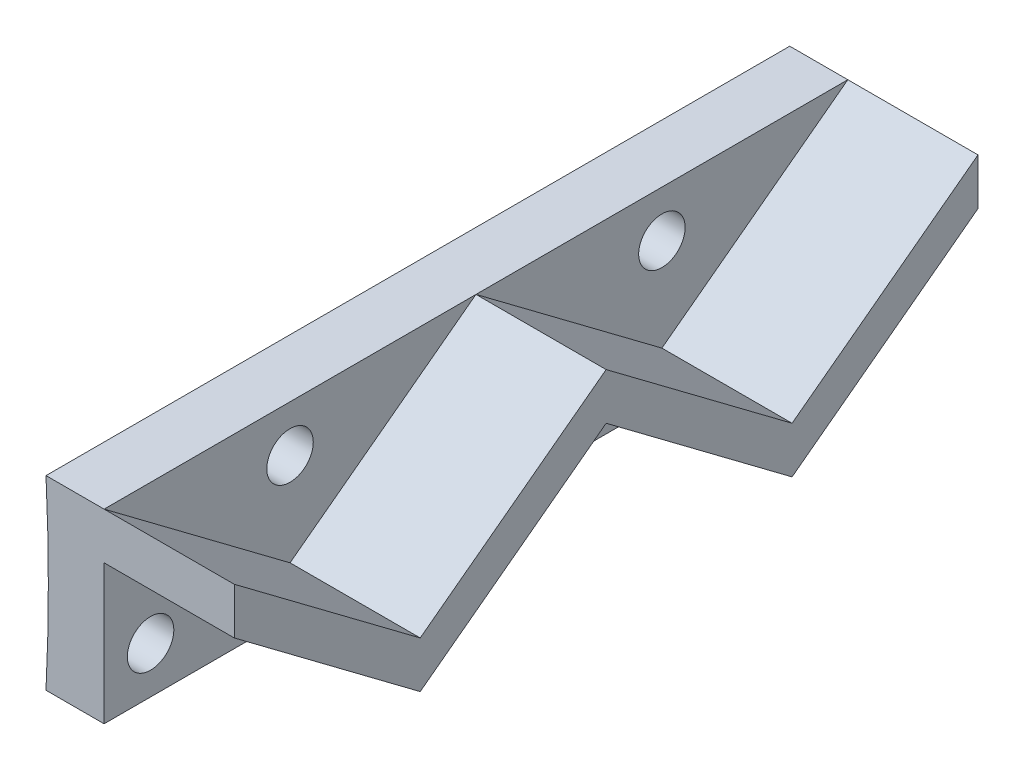
from build123d import *

# Parameters (mm, degrees)
SKETCH1_R           = 127
BOSS_EXTRUDE1_DEPTH = 50.8
SKETCH2_W           = 25.4
SKETCH2_H           = 12.7
SKETCH2_R           = 1.5875
BOSS_EXTRUDE2_DEPTH = 15.24
SKETCH2_4_R         = 1.5875
CUT_EXTRUDE1_DEPTH  = 8.89
LPATTERN1_COUNT     = 2
LPATTERN1_PITCH     = 25.4
SKETCH1_2_R         = 127
CUT_EXTRUDE2_DEPTH  = 196.514014843


with BuildPart() as part:
    # Sketch1 → Boss-Extrude1 (new body)
    with BuildSketch(Plane.XY):
        Circle(SKETCH1_R)
    extrude(amount=BOSS_EXTRUDE1_DEPTH)


with BuildPart() as body_2:
    # Sketch2 → Boss-Extrude2 (new body)
    with BuildSketch(Plane(origin=(139.7, 0, 0), x_dir=(0, 0, -1), z_dir=(1, 0, 0))):
        with Locations((-12.7, 0)):
            Rectangle(SKETCH2_W, SKETCH2_H)
        with Locations((-3.175, -3.175)):
            Circle(SKETCH2_R, mode=Mode.SUBTRACT)
        with Locations((-22.225, -3.175)):
            Circle(SKETCH2_R, mode=Mode.SUBTRACT)
        with Locations((-12.7, 3.175)):
            Circle(SKETCH2_R, mode=Mode.SUBTRACT)
    extrude(amount=-BOSS_EXTRUDE2_DEPTH)

    # Sketch2_4 → Cut-Extrude1 (cut)
    # profile 1 of 3: a face of its own
    with BuildSketch(Plane(origin=(139.7, 0, 0), x_dir=(0, 0, -1), z_dir=(1, 0, 0))):
        Polygon((0, -6.35), (0, 3.175), (-12.7, -6.35), align=None)
        with Locations((-3.175, -3.175)):
            Circle(SKETCH2_4_R, mode=Mode.SUBTRACT)
    # profile 2 of 3: a face of its own
    with BuildSketch(Plane(origin=(139.7, 0, 0), x_dir=(0, 0, -1), z_dir=(1, 0, 0))):
        Polygon((-12.7, -3.175), (0, 6.35), (-25.4, 6.35), align=None)
        with Locations((-12.7, 3.175)):
            Circle(SKETCH2_4_R, mode=Mode.SUBTRACT)
    # profile 3 of 3: a face of its own
    with BuildSketch(Plane(origin=(139.7, 0, 0), x_dir=(0, 0, -1), z_dir=(1, 0, 0))):
        Polygon((-25.4, -6.35), (-12.7, -6.35), (-25.4, 3.175), align=None)
        with Locations((-22.225, -3.175)):
            Circle(SKETCH2_4_R, mode=Mode.SUBTRACT)
    extrude(amount=-CUT_EXTRUDE1_DEPTH, mode=Mode.SUBTRACT)


with BuildPart() as lpattern1_1:
    # LPattern1: pattern copy
    add(body_2.part.moved(Location(Vector(0, 0, 1) * (1 * LPATTERN1_PITCH))))

    # Combine1: union body 2
    add(body_2.part)


with BuildPart() as cut_extrude2_tool:
    # Sketch1_2 → Cut-Extrude2 (new, through all)
    with BuildSketch(Plane.XY):
        Circle(SKETCH1_2_R)
    extrude(amount=CUT_EXTRUDE2_DEPTH)


with BuildPart() as part_1:
    add(part.part)

    # Cut-Extrude2: cut by cut_extrude2_tool
    add(cut_extrude2_tool.part, mode=Mode.SUBTRACT)


with BuildPart() as lpattern1_1_1:
    add(lpattern1_1.part)

    # Cut-Extrude2: cut by cut_extrude2_tool
    add(cut_extrude2_tool.part, mode=Mode.SUBTRACT)


solid = lpattern1_1_1.part
